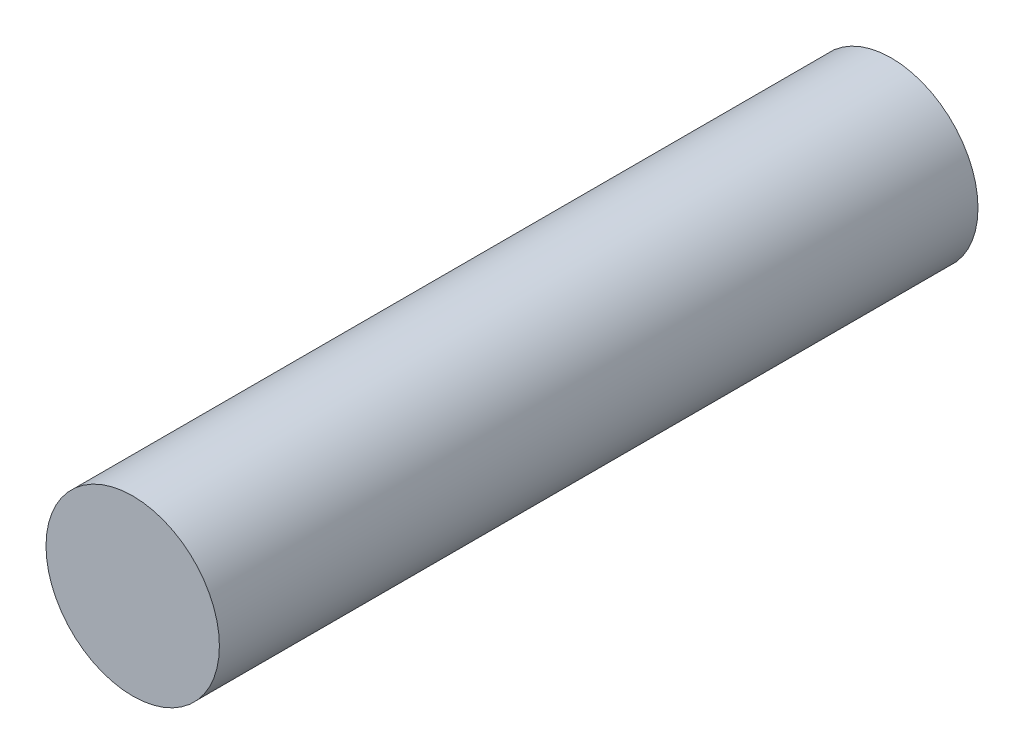
from build123d import *

# Parameters (mm, degrees)
SKETCH1_W    = 4
SKETCH1_H    = 35
SCALE1_SCALE = 0.5


with BuildPart() as part:
    # Sketch1 → Revolve1 (revolve)
    with BuildSketch(Plane(origin=(0, 0, 0), x_dir=(1, 0, 0), z_dir=(0, 1, 0))):
        with Locations((2, 17.5)):
            Rectangle(SKETCH1_W, SKETCH1_H)
    revolve(axis=Axis((0, 0, 0), (0, 0, -1)))


with BuildPart() as part_1:
    # Scale1: scaled about (0, 0, -17.5)
    add(part.part.scale(SCALE1_SCALE).moved(Location((0, 0, -8.75))))


solid = part_1.part
